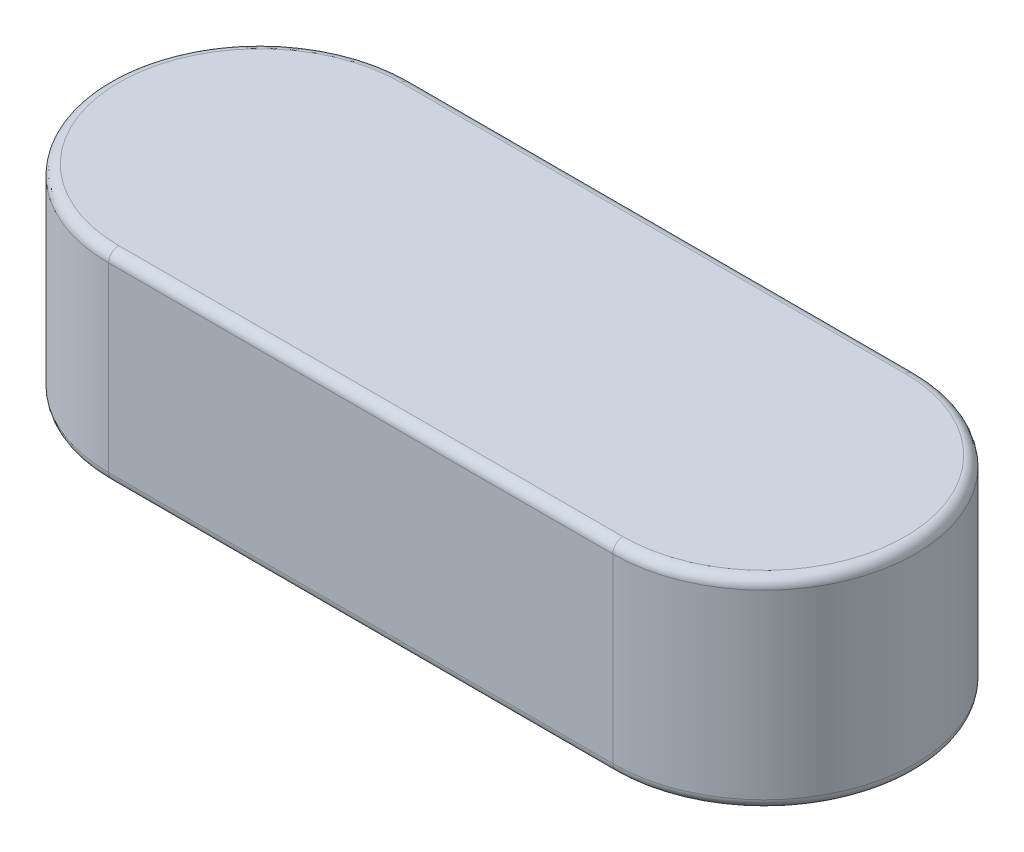
from build123d import *

# Parameters (mm, degrees)
EXTRUDE1_DEPTH = 8
FILLET1_R      = 0.4


with BuildPart() as part:
    # Sketch1 → Extrude1 (new body)
    with BuildSketch(Plane(origin=(0, 0, 0), x_dir=(1, 0, 0), z_dir=(0, 1, 0))):
        with BuildLine():
            Line((-20, 6), (0, 6))
            ThreePointArc((0, 6), (6, 0), (0, -6))
            Line((0, -6), (-20, -6))
            ThreePointArc((-20, -6), (-26, 0), (-20, 6))
        make_face()
    extrude(amount=EXTRUDE1_DEPTH)

    # Fillet1
    fillet1_edges = [part.edges().sort_by_distance(p)[0] for p in [
        (6, 8, 0),
        (-10, 8, -6),
        (-26, 8, 0),
        (-10, 0, -6),
        (6, 0, 0),
        (-10, 0, 6),
        (-26, 0, 0),
        (-10, 8, 6),
    ]]
    fillet(fillet1_edges, radius=FILLET1_R)


solid = part.part
